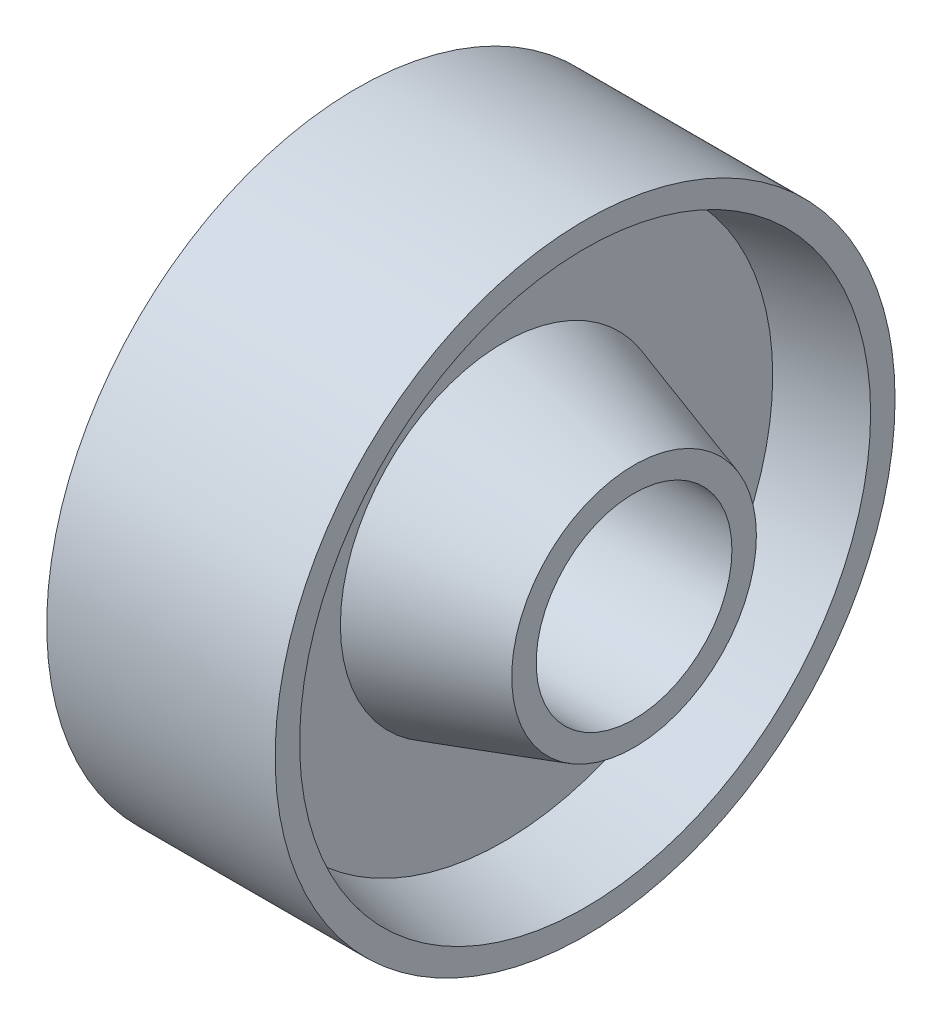
from build123d import *


with BuildPart() as part:
    # Sketch1 → Revolve1 (revolve)
    with BuildSketch(Plane.XY):
        Polygon((20, 12), (20, 15), (4, 20), (4, 33), (14, 35), (14, 38), (-14, 38), (-14, 35), (-4, 33), (-4, 20), (-20, 15), (-20, 12), align=None)
    revolve(axis=Axis((90.00864964, 0, 0), (-1, 0, 0)))


solid = part.part
